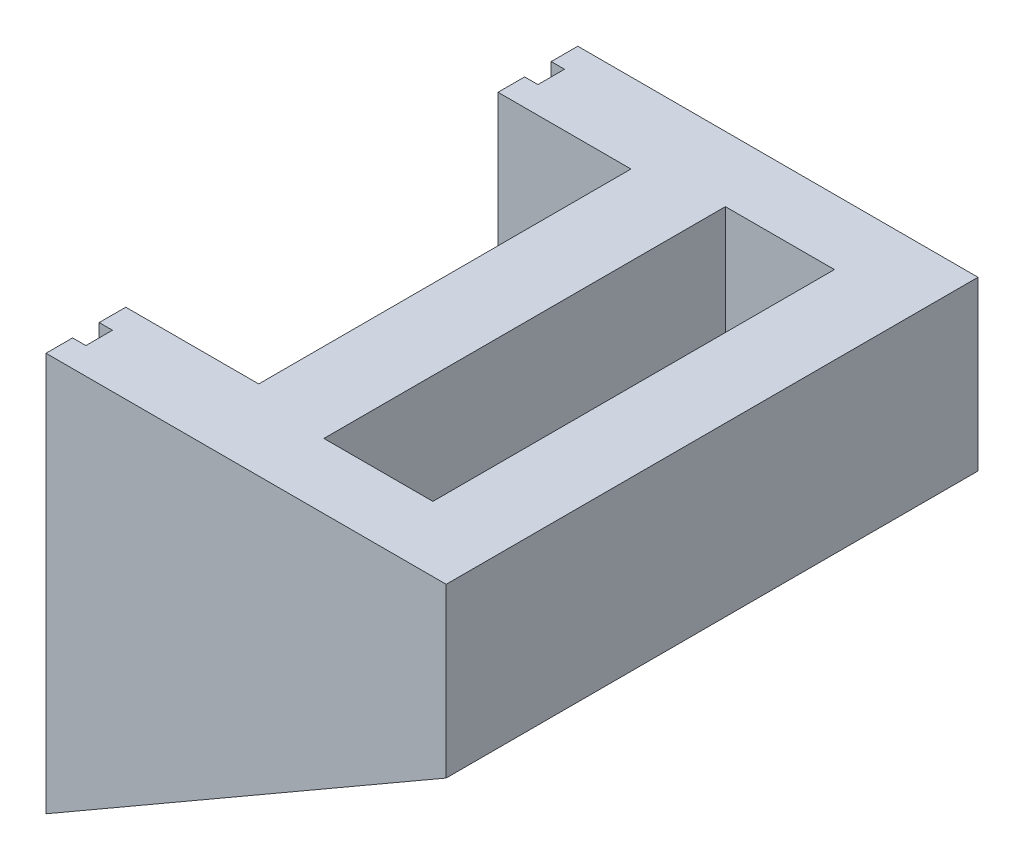
from build123d import *

# Parameters (mm, degrees)
SKETCH2_W           = 10
SKETCH2_H           = 20
BOSS_EXTRUDE1_DEPTH = 15
SKETCH3_W           = 4.1
SKETCH3_H           = 15.1
CUT_EXTRUDE1_DEPTH  = 16
SKETCH4_W           = 2.95
SKETCH4_H           = 2.45
CUT_EXTRUDE2_DEPTH  = 15
SKETCH6_W           = 20
SKETCH6_H           = 15
BOSS_EXTRUDE2_DEPTH = 3
BOSS_EXTRUDE3_DEPTH = 5
CUT_EXTRUDE3_DEPTH  = 21
CUT_EXTRUDE4_DEPTH  = 0.5


with BuildPart() as part:
    # Sketch2 → Boss-Extrude1 (new body)
    with BuildSketch(Plane(origin=(0, 0, 0), x_dir=(1, 0, 0), z_dir=(0, 1, 0))):
        Rectangle(SKETCH2_W, SKETCH2_H)
    extrude(amount=BOSS_EXTRUDE1_DEPTH)

    # Sketch3 → Cut-Extrude1 (cut, through all)
    with BuildSketch(Plane(origin=(0, 15, 0), x_dir=(1, 0, 0), z_dir=(0, 1, 0))):
        Rectangle(SKETCH3_W, SKETCH3_H)
    extrude(amount=-CUT_EXTRUDE1_DEPTH, mode=Mode.SUBTRACT)

    # Sketch4 → Cut-Extrude2 (cut)
    with BuildSketch(Plane(origin=(0, 15, 0), x_dir=(1, 0, 0), z_dir=(0, 1, 0))):
        Polygon((-2.05, 10), (-5, 10), (-5, -7.55), (-2.05, -7.55), (-2.05, 7.55), align=None)
        with Locations((-3.525, -8.775)):
            Rectangle(SKETCH4_W, SKETCH4_H)
    extrude(amount=-CUT_EXTRUDE2_DEPTH, mode=Mode.SUBTRACT)

    # Sketch6 → Boss-Extrude2 (add)
    with BuildSketch(Plane.ZY.offset(2.05)):
        with Locations((0, 7.5)):
            Rectangle(SKETCH6_W, SKETCH6_H)
    extrude(amount=BOSS_EXTRUDE2_DEPTH)

    # Sketch8 → Boss-Extrude3 (add)
    with BuildSketch(Plane.ZY.offset(5.05)):
        Polygon((-7, 15), (-10, 15), (-10, 0), (10, 0), (10, 15), (7, 15), (7, 3), (-7, 3), align=None)
    extrude(amount=BOSS_EXTRUDE3_DEPTH)

    # Sketch10 → Cut-Extrude3 (cut, through all)
    with BuildSketch(Plane.XY.offset(10)):
        Polygon((-10.05, 0), (5, 8.689121551), (5, 0), align=None)
    extrude(amount=-CUT_EXTRUDE3_DEPTH, mode=Mode.SUBTRACT)

    # Sketch11 → Cut-Extrude4 (cut)
    with BuildSketch(Plane.ZY.offset(10.05)):
        Polygon((-8, 2), (-8, 15), (-9, 15), (-9, 1), (0, 1), (9, 1), (9, 15), (8, 15), (8, 2), (0, 2), align=None)
    extrude(amount=-CUT_EXTRUDE4_DEPTH, mode=Mode.SUBTRACT)


solid = part.part
